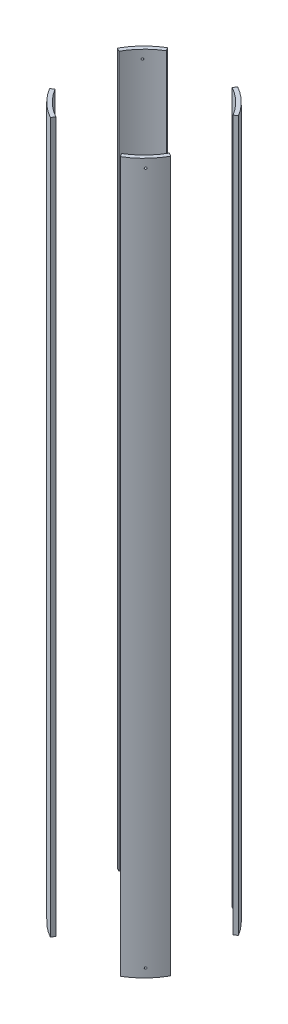
from build123d import *

# Parameters (mm, degrees)
SKETCH2_R               = 88.9
SKETCH2_R_2             = 83.82
BOSS_EXTRUDE1_DEPTH     = 458.60716
CUT_EXTRUDE1_DEPTH      = 459.60716
CUT_EXTRUDE1_DEPTH_BACK = 459.60716
SKETCH5_R               = 1.27
BOLT_HOLES_DEPTH        = 29.911624556
BOLT_PATTERN_COUNT      = 4


with BuildPart() as part:
    # Sketch2 → Boss-Extrude1 (new body, symmetric)
    with BuildSketch(Plane(origin=(0, 0, 0), x_dir=(1, 0, 0), z_dir=(0, 1, 0))):
        Circle(SKETCH2_R)
        Circle(SKETCH2_R_2, mode=Mode.SUBTRACT)
    extrude(amount=BOSS_EXTRUDE1_DEPTH, both=True)

    # Sketch3 → Cut-Extrude1 (cut, two sides)
    with BuildSketch(Plane(origin=(0, 0, 0), x_dir=(1, 0, 0), z_dir=(0, 1, 0))) as cut_extrude1_sk:
        Polygon((169.661755759, -94.300371224), (0, 0), (169.661755759, 101.677593364), align=None)
        Polygon((0, 0), (53.900027233, 96.974944394), (-58.116685864, 96.974944394), align=None)
        Polygon((-123.741299607, 68.777140945), (-123.741299607, -74.157652604), (0, 0), align=None)
        Polygon((-65.840936026, -118.45858783), (0, 0), (70.991745134, -118.45858783), align=None)
    extrude(amount=CUT_EXTRUDE1_DEPTH, mode=Mode.SUBTRACT)
    extrude(cut_extrude1_sk.sketch, amount=-CUT_EXTRUDE1_DEPTH_BACK, mode=Mode.SUBTRACT)

    # Sketch5 → Bolt holes (cut, through all)
    with BuildSketch(Plane(origin=(-56.309218645, 0, 58.175814955), x_dir=(-0.718540152, 0, -0.695485478), z_dir=(0.695485478, 0, -0.718540152))):
        with Locations((-0.02278764, 447.49466)):
            Circle(SKETCH5_R)
        with Locations((-0.02278764, -447.49466)):
            Circle(SKETCH5_R)
    bolt_holes = extrude(amount=-BOLT_HOLES_DEPTH, mode=Mode.SUBTRACT)

    # Bolt pattern: Bolt holes ×4 about axis
    bolt_pattern_axis = Axis((0, 458.60716, 0), (0, 1, 0))
    for i in range(1, BOLT_PATTERN_COUNT):
        add(bolt_holes.rotate(bolt_pattern_axis, i * 360 / BOLT_PATTERN_COUNT), mode=Mode.SUBTRACT)


solid = part.part
